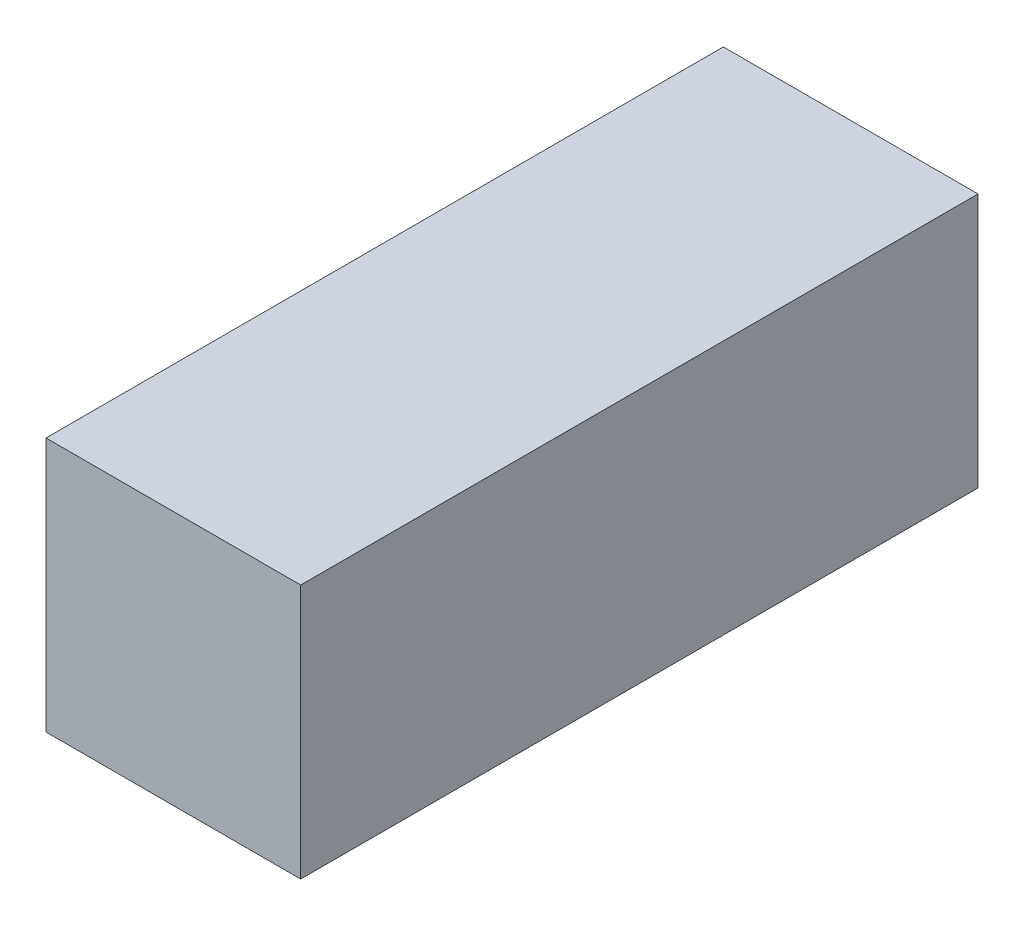
from build123d import *

# Parameters (mm, degrees)
SKETCH1_W           = 4.7752
SKETCH1_H           = 4.7752
BOSS_EXTRUDE1_DEPTH = 12.7


with BuildPart() as part:
    # Sketch1 → Boss-Extrude1 (new body)
    with BuildSketch(Plane.XY):
        with Locations((2.3876, 2.3876)):
            Rectangle(SKETCH1_W, SKETCH1_H)
    extrude(amount=BOSS_EXTRUDE1_DEPTH)


solid = part.part
